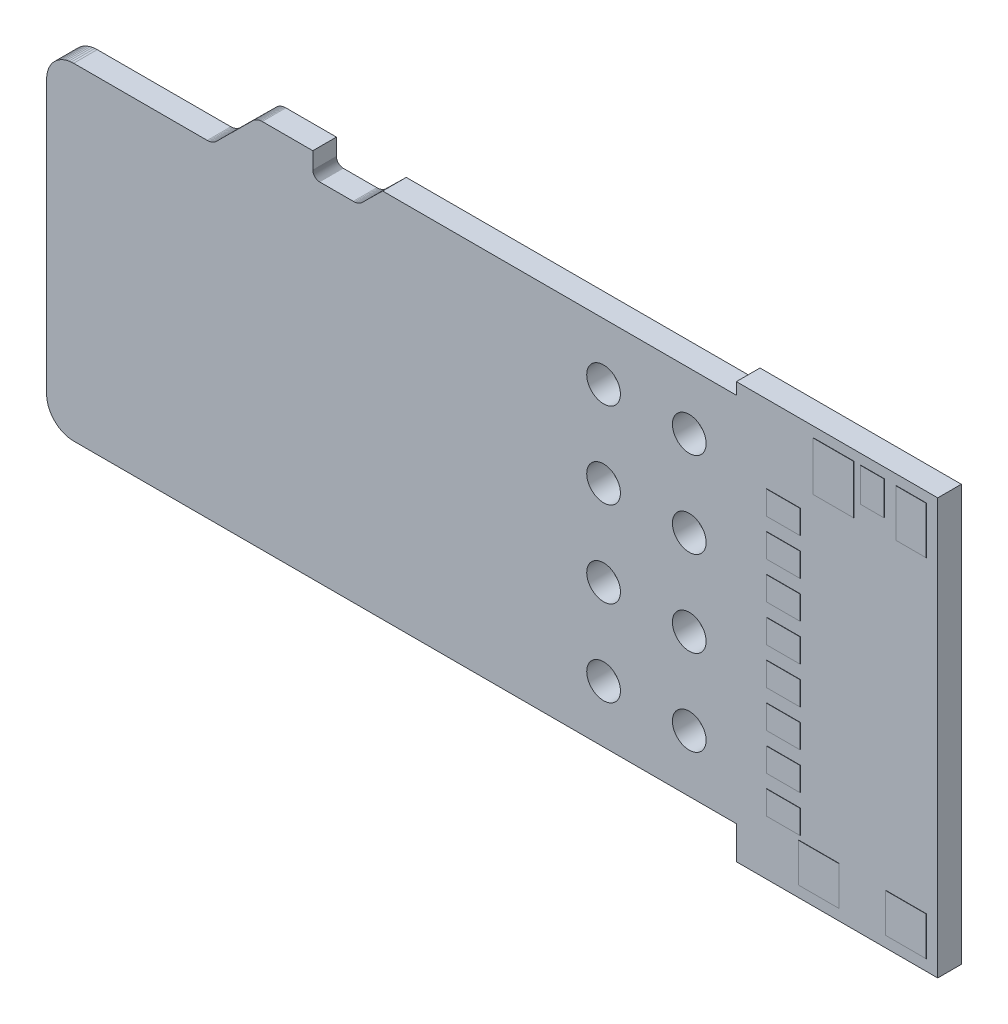
from build123d import *

# Parameters (mm, degrees)
AUFSATZ_LINEAR_AUSTRAGEN1_DEPTH      = 0.7
SOLDERMASK_BOTTOM_W                  = 2.9
SOLDERMASK_BOTTOM_H                  = 0.8
SOLDERMASK_BOTTOM_W_2                = 3.2
AUFSATZ_LINEAR_AUSTRAGEN2_DEPTH      = 0.01
AUFSATZ_LINEAR_START                 = 0.7
SOLDERMASK_TOP_W                     = 1.2
SOLDERMASK_TOP_H                     = 1.15
SOLDERMASK_TOP_W_2                   = 1
SOLDERMASK_TOP_H_2                   = 0.7
SOLDERMASK_TOP_H_3                   = 1.45
SOLDERMASK_TOP_W_3                   = 0.9
SOLDERMASK_TOP_H_4                   = 1.4
SOLDERMASK_TOP_W_4                   = 0.7
SOLDERMASK_TOP_H_5                   = 1
AUFSATZ_LINEAR_AUSTRAGEN3_DEPTH      = 0.01
BOHRUNG_R                            = 0.5
SCHNITT_LINEAR_AUSTRAGEN1_DEPTH      = 1.71
SCHNITT_LINEAR_AUSTRAGEN1_DEPTH_BACK = 1.01


with BuildPart() as part:
    # BOARD_OUTLINE → Aufsatz-Linear austragen1 (new body)
    with BuildSketch(Plane.XY):
        Polygon((15, 5.5), (20.447, 5.5), (20.447, 5.85), (26.416, 5.85), (26.416, -6.477), (20.447, -6.477), (20.447, -5.5), (15, -5.5), (0.8, -5.5), (0.730275, -5.496955), (0.661081, -5.487846), (0.592944, -5.47274), (0.526383, -5.451754), (0.461905, -5.425046), (0.399999, -5.39282), (0.341138, -5.355321), (0.285769, -5.312835), (0.234314, -5.265685), (0.187164, -5.21423), (0.144678, -5.158861), (0.107179, -5.099999), (0.074953, -5.038094), (0.048245, -4.973616), (0.027259, -4.907055), (0.012153, -4.838918), (0.003044, -4.769724), (0, -4.7), (0, 3.399999), (0.002742, 3.462798), (0.011579, 3.532347), (0.026444, 3.600861), (0.047224, 3.667819), (0.07376, 3.732711), (0.105851, 3.795043), (0.143253, 3.854342), (0.185681, 3.910154), (0.232811, 3.962057), (0.284286, 4.009654), (0.339714, 4.052584), (0.398672, 4.09052), (0.460712, 4.123172), (0.525361, 4.150294), (0.592129, 4.171677), (0.660506, 4.18716), (0.729973, 4.196625), (0.8, 4.199999), (4.759999, 4.2), (4.795092, 4.202141), (4.829864, 4.207333), (4.864051, 4.215535), (4.897393, 4.226686), (4.929637, 4.240701), (4.960536, 4.257472), (4.989856, 4.276872), (5.017374, 4.298755), (5.039999, 4.32), (6.11, 5.38), (6.13414, 5.402667), (6.161528, 5.424318), (6.190698, 5.4435), (6.22143, 5.460066), (6.253489, 5.473891), (6.28663, 5.484869), (6.320602, 5.492916), (6.355146, 5.497973), (6.39, 5.499999), (7.89, 5.5), (7.89, 5), (7.891159, 4.982203), (7.893866, 4.964575), (7.898098, 4.94725), (7.903825, 4.93036), (7.911001, 4.914034), (7.919574, 4.898395), (7.929476, 4.883562), (7.940634, 4.86965), (7.952962, 4.856762), (7.966366, 4.844998), (7.980745, 4.834447), (7.995988, 4.82519), (8.01198, 4.817296), (8.0286, 4.810826), (8.04572, 4.805829), (8.06321, 4.802343), (8.080938, 4.800395), (8.09, 4.8), (9.089999, 4.8), (9.124473, 4.801844), (9.158654, 4.806685), (9.192283, 4.814486), (9.225104, 4.825189), (9.256868, 4.838712), (9.287332, 4.854952), (9.316265, 4.873785), (9.343446, 4.895068), (9.368669, 4.918639), (9.369998, 4.920001), (9.96, 5.5), align=None)
    extrude(amount=AUFSATZ_LINEAR_AUSTRAGEN1_DEPTH)

    # SOLDERMASK_BOTTOM → Aufsatz-Linear austragen2 (add)
    with BuildSketch(Plane.XY):
        with Locations((2.95, -4.5)):
            Rectangle(SOLDERMASK_BOTTOM_W, SOLDERMASK_BOTTOM_H)
        with Locations((2.95, -3.4)):
            Rectangle(SOLDERMASK_BOTTOM_W, SOLDERMASK_BOTTOM_H)
        with Locations((2.8, -2.3)):
            Rectangle(SOLDERMASK_BOTTOM_W_2, SOLDERMASK_BOTTOM_H)
        with Locations((2.95, -1.2)):
            Rectangle(SOLDERMASK_BOTTOM_W, SOLDERMASK_BOTTOM_H)
        with Locations((2.8, -0.1)):
            Rectangle(SOLDERMASK_BOTTOM_W_2, SOLDERMASK_BOTTOM_H)
        with Locations((2.95, 1)):
            Rectangle(SOLDERMASK_BOTTOM_W, SOLDERMASK_BOTTOM_H)
        with Locations((2.95, 2.1)):
            Rectangle(SOLDERMASK_BOTTOM_W, SOLDERMASK_BOTTOM_H)
        with Locations((2.95, 3.2)):
            Rectangle(SOLDERMASK_BOTTOM_W, SOLDERMASK_BOTTOM_H)
    extrude(amount=-AUFSATZ_LINEAR_AUSTRAGEN2_DEPTH)

    # SOLDERMASK_TOP → Aufsatz-Linear austragen3 (add)
    with BuildSketch(Plane.XY.offset(AUFSATZ_LINEAR_START)):
        with Locations((22.894, -5.57)):
            Rectangle(SOLDERMASK_TOP_W, SOLDERMASK_TOP_H)
        with Locations((25.484, -5.57)):
            Rectangle(SOLDERMASK_TOP_W, SOLDERMASK_TOP_H)
        with Locations((21.844, -4.5)):
            Rectangle(SOLDERMASK_TOP_W_2, SOLDERMASK_TOP_H_2)
        with Locations((21.844, -3.4)):
            Rectangle(SOLDERMASK_TOP_W_2, SOLDERMASK_TOP_H_2)
        with Locations((21.844, -2.3)):
            Rectangle(SOLDERMASK_TOP_W_2, SOLDERMASK_TOP_H_2)
        with Locations((21.844, -1.2)):
            Rectangle(SOLDERMASK_TOP_W_2, SOLDERMASK_TOP_H_2)
        with Locations((21.844, -0.1)):
            Rectangle(SOLDERMASK_TOP_W_2, SOLDERMASK_TOP_H_2)
        with Locations((21.844, 1)):
            Rectangle(SOLDERMASK_TOP_W_2, SOLDERMASK_TOP_H_2)
        with Locations((21.844, 2.1)):
            Rectangle(SOLDERMASK_TOP_W_2, SOLDERMASK_TOP_H_2)
        with Locations((21.844, 3.2)):
            Rectangle(SOLDERMASK_TOP_W_2, SOLDERMASK_TOP_H_2)
        with Locations((23.334, 4.825)):
            Rectangle(SOLDERMASK_TOP_W, SOLDERMASK_TOP_H_3)
        with Locations((25.634, 4.85)):
            Rectangle(SOLDERMASK_TOP_W_3, SOLDERMASK_TOP_H_4)
        with Locations((24.484, 5.05)):
            Rectangle(SOLDERMASK_TOP_W_4, SOLDERMASK_TOP_H_5)
    extrude(amount=AUFSATZ_LINEAR_AUSTRAGEN3_DEPTH)

    # BOHRUNG → Schnitt-Linear austragen1 (cut, two sides)
    with BuildSketch(Plane.XY) as schnitt_linear_austragen1_sk:
        with Locations((16.51, -3.81)):
            Circle(BOHRUNG_R)
        with Locations((19.05, -3.81)):
            Circle(BOHRUNG_R)
        with Locations((16.51, -1.27)):
            Circle(BOHRUNG_R)
        with Locations((19.05, -1.27)):
            Circle(BOHRUNG_R)
        with Locations((16.51, 1.27)):
            Circle(BOHRUNG_R)
        with Locations((19.05, 1.27)):
            Circle(BOHRUNG_R)
        with Locations((16.51, 3.81)):
            Circle(BOHRUNG_R)
        with Locations((19.05, 3.81)):
            Circle(BOHRUNG_R)
    extrude(amount=SCHNITT_LINEAR_AUSTRAGEN1_DEPTH, mode=Mode.SUBTRACT)
    extrude(schnitt_linear_austragen1_sk.sketch, amount=-SCHNITT_LINEAR_AUSTRAGEN1_DEPTH_BACK, mode=Mode.SUBTRACT)


solid = part.part
